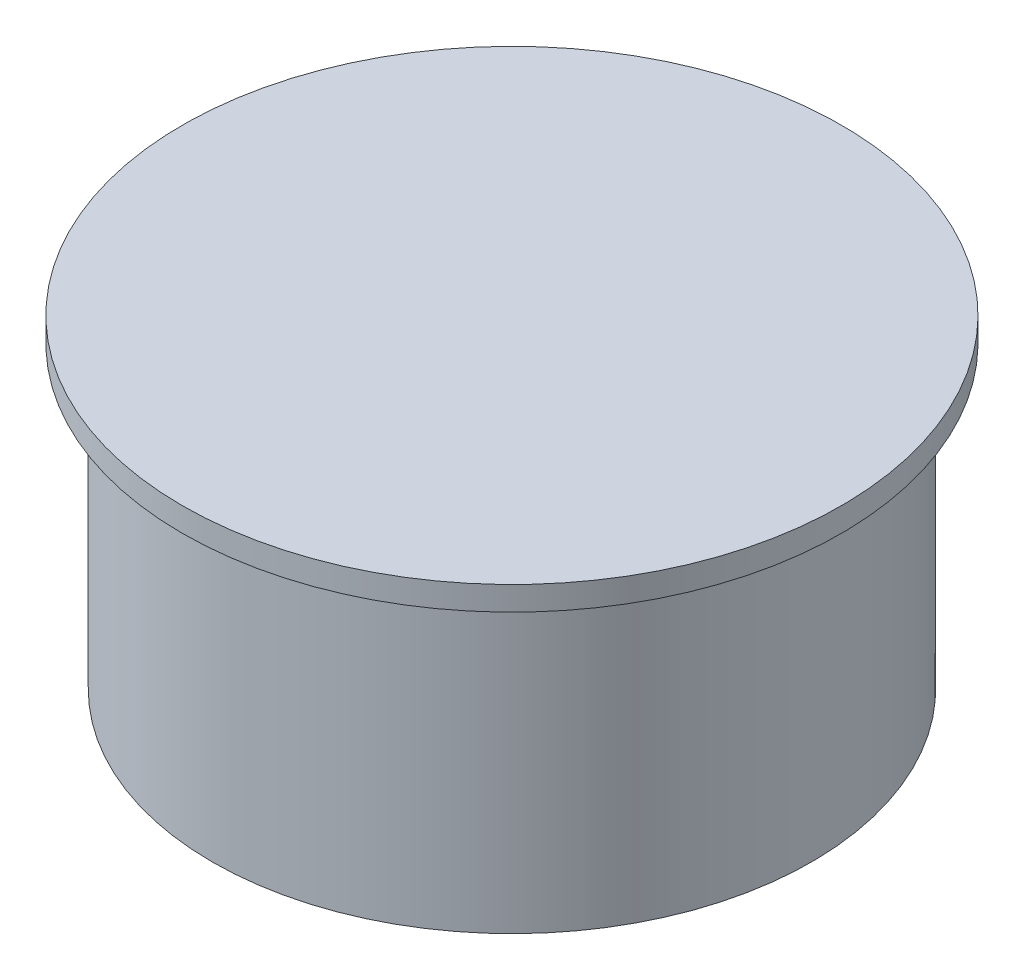
from build123d import *

# Parameters (mm, degrees)
SKETCH1_R           = 5
BOSS_EXTRUDE1_DEPTH = 5
SKETCH2_R           = 5.5
BOSS_EXTRUDE2_DEPTH = 0.4


with BuildPart() as part:
    # Sketch1 → Boss-Extrude1 (new body)
    with BuildSketch(Plane(origin=(0, 0, 0), x_dir=(1, 0, 0), z_dir=(0, 1, 0))):
        Circle(SKETCH1_R)
    extrude(amount=BOSS_EXTRUDE1_DEPTH)

    # Sketch2 → Boss-Extrude2 (add)
    with BuildSketch(Plane(origin=(0, 5, 0), x_dir=(1, 0, 0), z_dir=(0, 1, 0))):
        Circle(SKETCH2_R)
    extrude(amount=BOSS_EXTRUDE2_DEPTH)


solid = part.part
